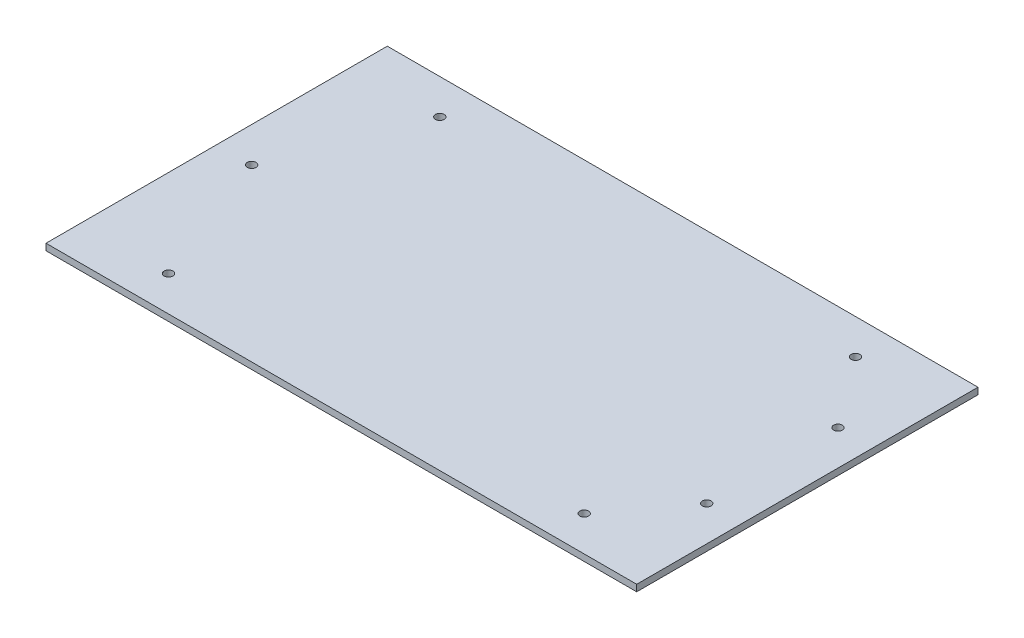
from build123d import *

# Parameters (mm, degrees)
SKETCH1_W               = 270
SKETCH1_H               = 156
BOSS_EXTRUDE1_DEPTH     = 3
CUT_EXTRUDE1_REACH      = 5
SKETCH2_R               = 2
SKETCH3_R               = 2
CUT_EXTRUDE2_DEPTH      = 3
MIRROR4_COPY_1_SKETCH_R = 2
MIRROR4_COPY_1_DEPTH    = 3
CUT_EXTRUDE4_REACH      = 5
SKETCH5_R               = 2


with BuildPart() as part:
    # Sketch1 → Boss-Extrude1 (new body)
    with BuildSketch(Plane(origin=(0, 0, 0), x_dir=(1, 0, 0), z_dir=(0, 1, 0))):
        Rectangle(SKETCH1_W, SKETCH1_H)
    extrude(amount=BOSS_EXTRUDE1_DEPTH)

    # Sketch2 → Cut-Extrude1 (cut, up to next)
    with BuildSketch(Plane(origin=(0, 3, 0), x_dir=(1, 0, 0), z_dir=(0, 1, 0)), mode=Mode.PRIVATE) as cut_extrude1_sk1:
        with Locations(Location((-119, 0, 0), (0, 0, 270))):  # turned: the seam where the file's is
            Circle(SKETCH2_R)
    cut_extrude1_tool1 = extrude(cut_extrude1_sk1.sketch, amount=-CUT_EXTRUDE1_REACH, mode=Mode.PRIVATE) & part.part
    add(cut_extrude1_tool1.solids().sort_by_distance((-119, 3, 0))[0], mode=Mode.SUBTRACT)

    # Sketch3 → Cut-Extrude2 (cut)
    with BuildSketch(Plane(origin=(0, 3, 0), x_dir=(1, 0, 0), z_dir=(0, 1, 0))):
        with Locations(Location((-95, 62, 0), (0, 0, 270))):  # turned: the seam where the file's is
            Circle(SKETCH3_R)
    cut_extrude2 = extrude(amount=-CUT_EXTRUDE2_DEPTH, mode=Mode.SUBTRACT)

    # Mirror3: Cut-Extrude2 across plane
    add(cut_extrude2.mirror(Plane(origin=(0, 0, 0), x_dir=(0, 0, 1), z_dir=(1, 0, 0))), mode=Mode.SUBTRACT)

    # Mirror4: Cut-Extrude2 across plane
    add(cut_extrude2.mirror(Plane.XY), mode=Mode.SUBTRACT)

    # Mirror4 copy 1 sketch → Mirror4 copy 1 (cut)
    with BuildSketch(Plane(origin=(0, 3, 0), x_dir=(-1, 0, 0), z_dir=(0, 1, 0))):
        with Locations(Location((-95, 62, 0), (0, 0, 270))):  # turned: the seam where the file's is
            Circle(MIRROR4_COPY_1_SKETCH_R)
    extrude(amount=-MIRROR4_COPY_1_DEPTH, mode=Mode.SUBTRACT)

    # Sketch5 → Cut-Extrude4 (cut, up to next)
    with BuildSketch(Plane(origin=(0, 3, 0), x_dir=(1, 0, 0), z_dir=(0, 1, 0)), mode=Mode.PRIVATE) as cut_extrude4_sk1:
        with Locations(Location((119, 30, 0), (0, 0, 270))):  # turned: the seam where the file's is
            Circle(SKETCH5_R)
    cut_extrude4_tool1 = extrude(cut_extrude4_sk1.sketch, amount=-CUT_EXTRUDE4_REACH, mode=Mode.PRIVATE) & part.part
    add(cut_extrude4_tool1.solids().sort_by_distance((119, 3, -30))[0], mode=Mode.SUBTRACT)
    # Sketch5 → Cut-Extrude4 (cut, up to next)
    with BuildSketch(Plane(origin=(0, 3, 0), x_dir=(1, 0, 0), z_dir=(0, 1, 0)), mode=Mode.PRIVATE) as cut_extrude4_sk2:
        with Locations(Location((119, -30, 0), (0, 0, 270))):  # turned: the seam where the file's is
            Circle(SKETCH5_R)
    cut_extrude4_tool2 = extrude(cut_extrude4_sk2.sketch, amount=-CUT_EXTRUDE4_REACH, mode=Mode.PRIVATE) & part.part
    add(cut_extrude4_tool2.solids().sort_by_distance((119, 3, 30))[0], mode=Mode.SUBTRACT)


solid = part.part
